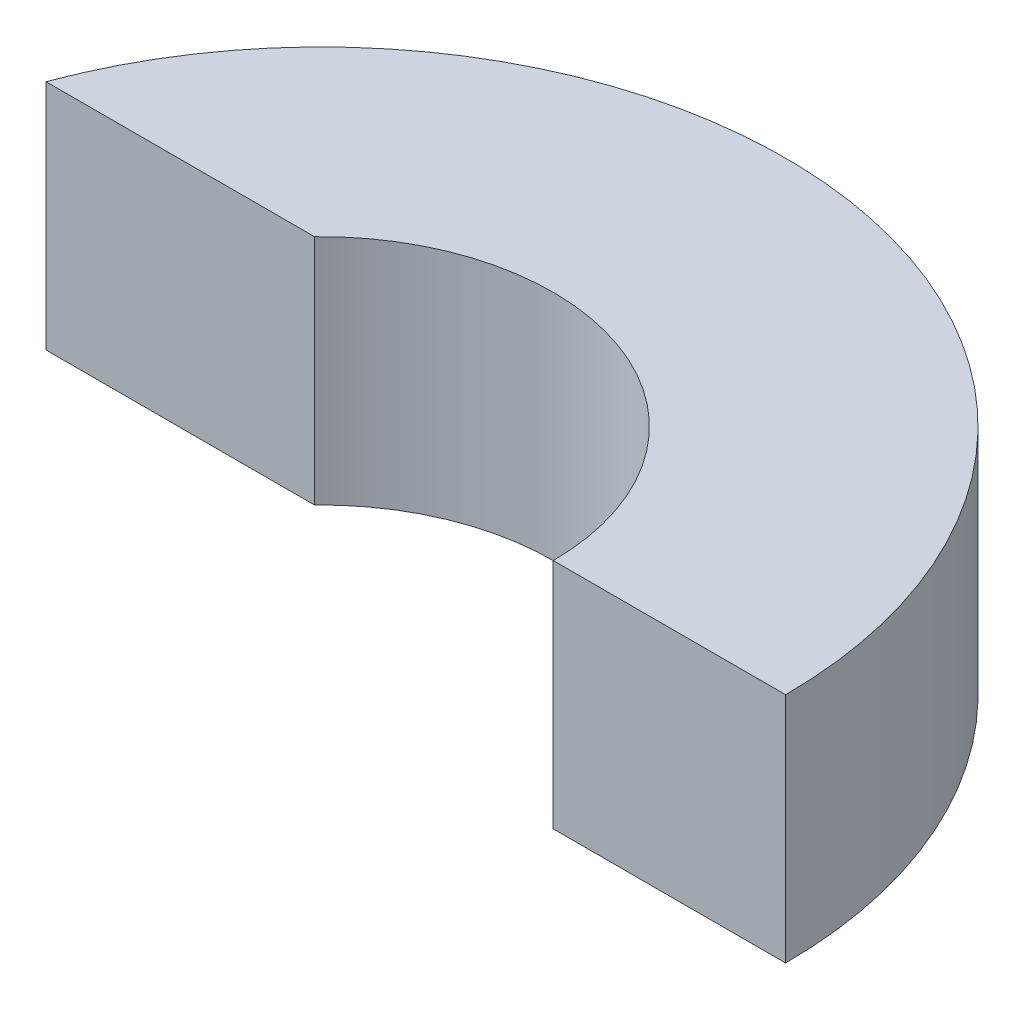
from build123d import *

# Parameters (mm, degrees)
BOSS_EXTRUDE1_DEPTH = 5


with BuildPart() as part:
    # Sketch1 → Boss-Extrude1 (new body)
    with BuildSketch(Plane(origin=(0, 0, 0), x_dir=(1, 0, 0), z_dir=(0, 1, 0))):
        with BuildLine():
            Line((5, 0), (10, 0))
            ThreePointArc((10, 0), (1.760763185, 9.843765184), (-9.379942601, 3.466507868))
            Line((-9.379942601, 3.466507868), (-3.603237877, 3.466507868))
            ThreePointArc((-3.603237877, 3.466507868), (1.868664043, 4.637682039), (5, 0))
        make_face()
    extrude(amount=BOSS_EXTRUDE1_DEPTH)


solid = part.part
